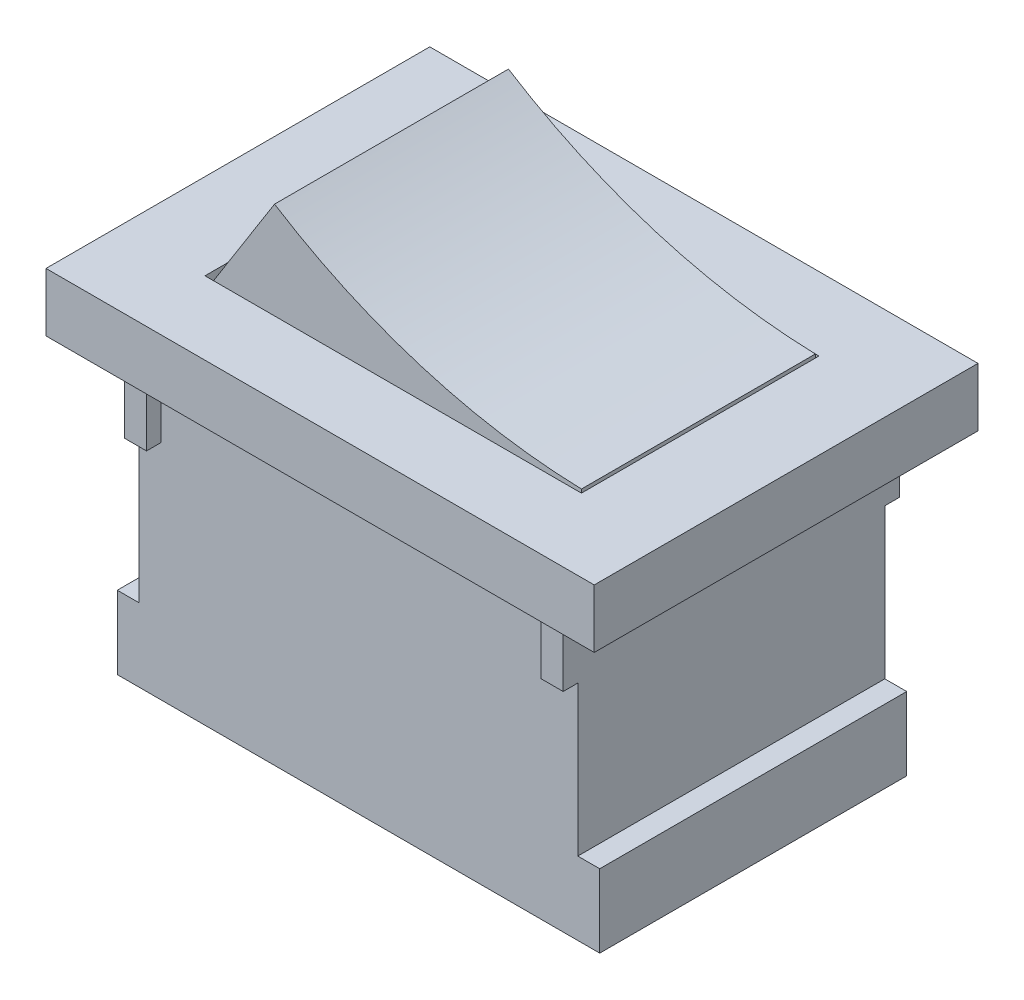
from build123d import *

# Parameters (mm, degrees)
SKETCH1_W           = 15
SKETCH1_H           = 10.5
BOSS_EXTRUDE1_DEPTH = 1.6
SKETCH2_W           = 10.3
SKETCH2_H           = 6.5
CUT_EXTRUDE1_DEPTH  = 1.5
SKETCH3_W           = 10.2
SKETCH3_H           = 6.4
BOSS_EXTRUDE2_DEPTH = 4.1
CUT_EXTRUDE4_DEPTH  = 6.4
SKETCH8_W           = 13.2
SKETCH8_H           = 8.4
BOSS_EXTRUDE5_DEPTH = 8.1
SKETCH9_W           = 0.6
SKETCH9_H           = 6.1
CUT_EXTRUDE30_DEPTH = 8.4
SKETCH10_W          = 0.6
SKETCH10_H          = 2
BOSS_EXTRUDE7_DEPTH = 0.4
LPATTERN3_COUNT     = 2
LPATTERN3_PITCH     = 8.8
SKETCH12_W          = 1.719741978
SKETCH12_H          = 6.045276093
BOSS_EXTRUDE8_DEPTH = 1.1
CUT_EXTRUDE42_DEPTH = 1.1


with BuildPart() as part:
    # Sketch1 → Boss-Extrude1 (new body)
    with BuildSketch(Plane(origin=(0, 0, 0), x_dir=(1, 0, 0), z_dir=(0, 1, 0))):
        Rectangle(SKETCH1_W, SKETCH1_H)
    extrude(amount=BOSS_EXTRUDE1_DEPTH)

    # Sketch2 → Cut-Extrude1 (cut)
    with BuildSketch(Plane(origin=(0, 1.6, 0), x_dir=(1, 0, 0), z_dir=(0, 1, 0))):
        Rectangle(SKETCH2_W, SKETCH2_H)
    extrude(amount=-CUT_EXTRUDE1_DEPTH, mode=Mode.SUBTRACT)

    # Sketch3 → Boss-Extrude2 (add)
    with BuildSketch(Plane(origin=(0, 0.1, 0), x_dir=(1, 0, 0), z_dir=(0, 1, 0))):
        Rectangle(SKETCH3_W, SKETCH3_H)
    extrude(amount=BOSS_EXTRUDE2_DEPTH)

    # Sketch4 → Cut-Extrude4 (cut)
    with BuildSketch(Plane.XY.offset(3.2)):
        Polygon((-5.1, 4.2), (-5.1, 1.33831827), (-3.296595892, 4.2), align=None)
        with BuildLine():
            Line((5.1, 4.2), (-3.296595892, 4.2))
            ThreePointArc((-3.296595892, 4.2), (0.730166495, 2.35961781), (5.1, 1.648016048))
            Line((5.1, 1.648016048), (5.1, 4.2))
        make_face()
    extrude(amount=-CUT_EXTRUDE4_DEPTH, mode=Mode.SUBTRACT)



with BuildPart() as body_2:
    # Sketch8 → Boss-Extrude5 (new body)
    with BuildSketch(Plane(origin=(0, 0, 0), x_dir=(-1, 0, 0), z_dir=(0, -1, 0))):
        Rectangle(SKETCH8_W, SKETCH8_H)
    extrude(amount=BOSS_EXTRUDE5_DEPTH)

    # Sketch9 → Cut-Extrude30 (cut)
    with BuildSketch(Plane.XY.offset(4.2)):
        with Locations((-6.3, -3.05)):
            Rectangle(SKETCH9_W, SKETCH9_H)
        with Locations((6.3, -3.05)):
            Rectangle(SKETCH9_W, SKETCH9_H)
    extrude(amount=-CUT_EXTRUDE30_DEPTH, mode=Mode.SUBTRACT)


with BuildPart() as part_1:
    add(part.part)

    add(body_2.part)  # Boss-Extrude7 merges body 2
    # Sketch10 → Boss-Extrude7 (add)
    with BuildSketch(Plane(origin=(0, 0, -4.2), x_dir=(-1, 0, 0), z_dir=(0, 0, -1))):
        with Locations((-5.7, -1)):
            Rectangle(SKETCH10_W, SKETCH10_H)
        with Locations((5.7, -1)):
            Rectangle(SKETCH10_W, SKETCH10_H)
    boss_extrude7 = extrude(amount=BOSS_EXTRUDE7_DEPTH)

    # LPattern3: Boss-Extrude7 ×2
    with Locations(*[(0, 0, i * LPATTERN3_PITCH) for i in range(1, LPATTERN3_COUNT)]):
        add(boss_extrude7)

    # Sketch12 → Boss-Extrude8 (add)
    with BuildSketch(Plane.ZY.offset(6)):
        with Locations((0, -3.045413524)):
            Rectangle(SKETCH12_W, SKETCH12_H)
    extrude(amount=BOSS_EXTRUDE8_DEPTH)

    # Sketch14 → Cut-Extrude42 (cut)
    with BuildSketch(Plane(origin=(0, 0, -0.859870989), x_dir=(-1, 0, 0), z_dir=(0, 0, -1))):
        Polygon((7.1, -0.022775477), (6.422538679, -0.022775477), (7.012651067, -3.06805157), (6.422765107, -6.06805157), (7.1, -6.06805157), align=None)
    extrude(amount=-CUT_EXTRUDE42_DEPTH, mode=Mode.SUBTRACT)


solid = part_1.part
